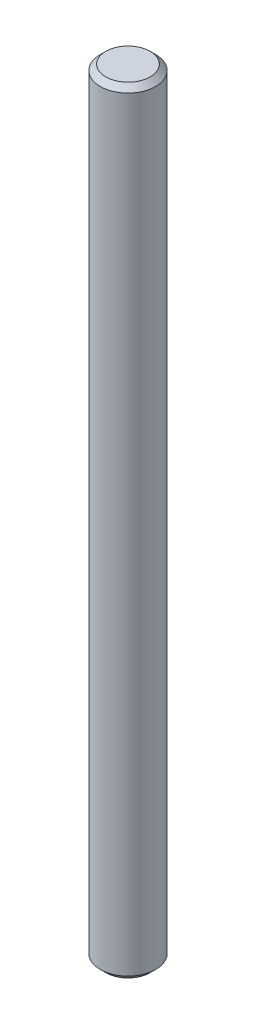
from build123d import *

# Parameters (mm, degrees)
SKETCH1_R           = 2.5
BOSS_EXTRUDE1_DEPTH = 70
CHAMFER1_SIZE       = 0.5


with BuildPart() as part:
    # Sketch1 → Boss-Extrude1 (new body)
    with BuildSketch(Plane(origin=(0, 0, 0), x_dir=(1, 0, 0), z_dir=(0, 1, 0))):
        Circle(SKETCH1_R)
    extrude(amount=BOSS_EXTRUDE1_DEPTH)

    # Chamfer1
    chamfer1_edges = [part.edges().sort_by_distance(p)[0] for p in [
        (-2.5, 0, 0),
        (-2.5, 70, 0),
    ]]
    chamfer(chamfer1_edges, length=CHAMFER1_SIZE)


solid = part.part
